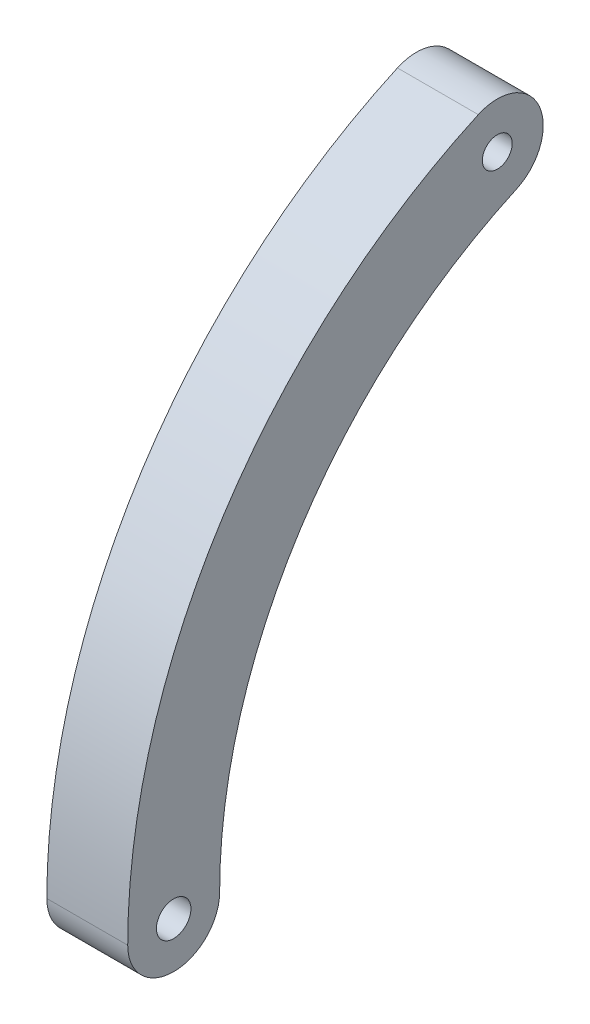
from build123d import *

# Parameters (mm, degrees)
ESQUISSE1_R        = 1.190625
ESQUISSE1_R_2      = 1.031875
BOSS_EXTRU_1_DEPTH = 5.588


with BuildPart() as part:
    # Esquisse1 → Boss.-Extru.1 (new body)
    with BuildSketch(Plane(origin=(0, 0, 0), x_dir=(0, 0, -1), z_dir=(1, 0, 0))):
        with BuildLine():
            ThreePointArc((-34.925, 0), (-29.357723625, 18.917708333), (-14.430815972, 31.804200593))
            ThreePointArc((-14.430815972, 31.804200593), (-12.85141737, 36.007383917), (-17.054600694, 37.586782519))
            ThreePointArc((-17.054600694, 37.586782519), (-34.695491556, 22.357291667), (-41.275, 0))
            ThreePointArc((-41.275, 0), (-38.1, -3.175), (-34.925, 0))
        make_face()
        with Locations((-38.1, 0)):
            Circle(ESQUISSE1_R, mode=Mode.SUBTRACT)
        with Locations((-15.742708333, 34.695491556)):
            Circle(ESQUISSE1_R_2, mode=Mode.SUBTRACT)
    extrude(amount=BOSS_EXTRU_1_DEPTH)


solid = part.part
